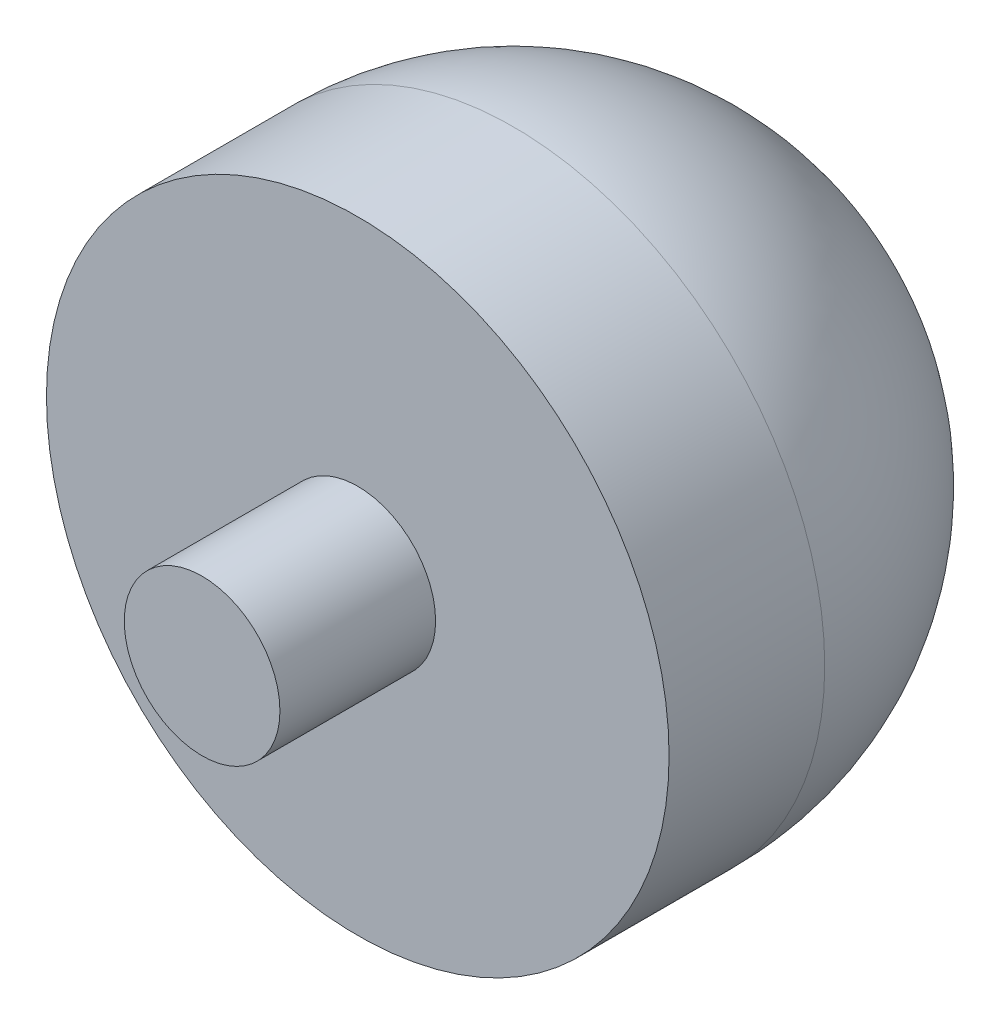
from build123d import *

# Parameters (mm, degrees)
SKETCH1_R           = 20
BOSS_EXTRUDE1_DEPTH = 30
SKETCH2_R           = 5
BOSS_EXTRUDE2_DEPTH = 10
FILLET1_R           = 20


with BuildPart() as part:
    # Sketch1 → Boss-Extrude1 (new body)
    with BuildSketch(Plane.XY):
        Circle(SKETCH1_R)
    extrude(amount=BOSS_EXTRUDE1_DEPTH)

    # Sketch2 → Boss-Extrude2 (add)
    with BuildSketch(Plane.XY.offset(30)):
        Circle(SKETCH2_R)
    extrude(amount=BOSS_EXTRUDE2_DEPTH)

    # Fillet1
    fillet1_edges = [part.edges().sort_by_distance(p)[0] for p in [
        (-20, 0, 0),
    ]]
    fillet(fillet1_edges, radius=FILLET1_R)


solid = part.part
